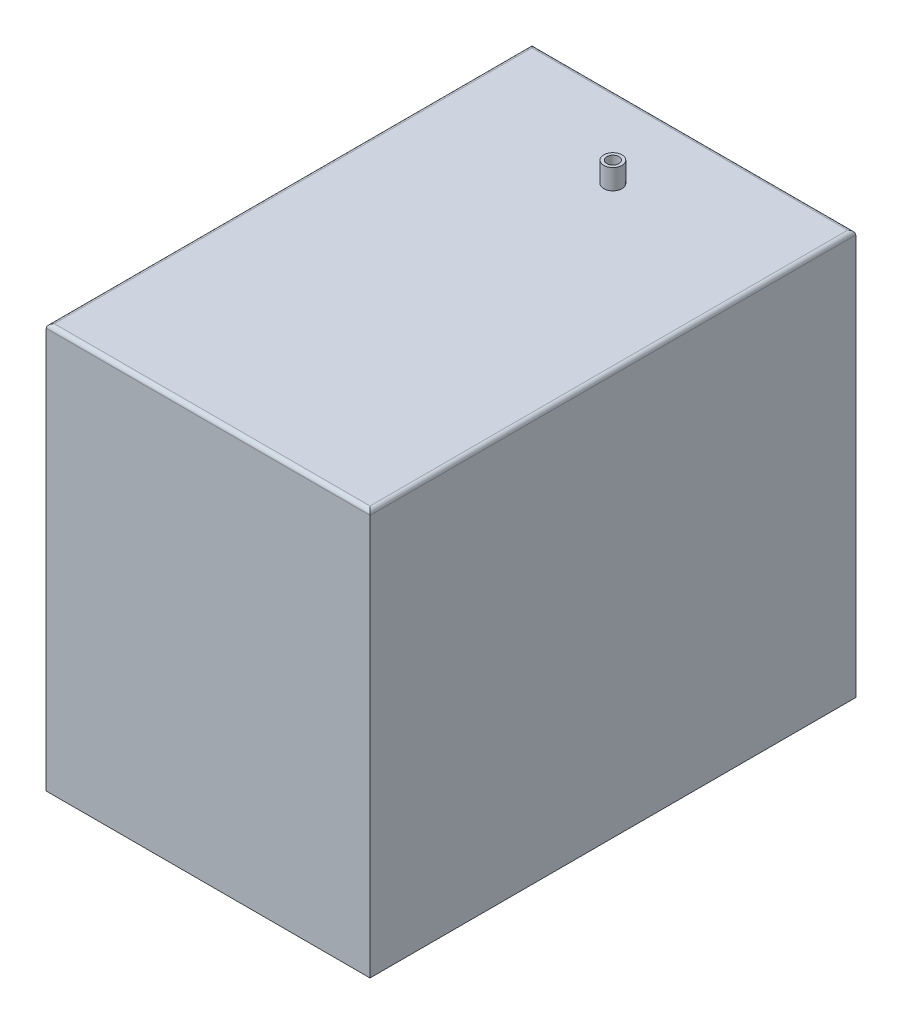
from build123d import *

# Parameters (mm, degrees)
SKETCH1_W           = 80
SKETCH1_H           = 120
BOSS_EXTRUDE1_DEPTH = 100
SKETCH2_R           = 2.25
SKETCH2_R_2         = 1.5
BOSS_EXTRUDE2_DEPTH = 5
FILLET1_R           = 1


with BuildPart() as part:
    # Sketch1 → Boss-Extrude1 (new body)
    with BuildSketch(Plane(origin=(0, 0, 0), x_dir=(1, 0, 0), z_dir=(0, 1, 0))):
        Rectangle(SKETCH1_W, SKETCH1_H)
    extrude(amount=BOSS_EXTRUDE1_DEPTH)

    # Sketch2 → Boss-Extrude2 (add)
    with BuildSketch(Plane(origin=(0, 100, 0), x_dir=(1, 0, 0), z_dir=(0, 1, 0))):
        with Locations((0, 40)):
            Circle(SKETCH2_R)
        with Locations((0, 40)):
            Circle(SKETCH2_R_2, mode=Mode.SUBTRACT)
    extrude(amount=BOSS_EXTRUDE2_DEPTH)

    # Fillet1
    fillet1_edges = [part.edges().sort_by_distance(p)[0] for p in [
        (-40, 100, 0),
        (0, 100, 60),
        (40, 100, 0),
        (0, 100, -60),
    ]]
    fillet(fillet1_edges, radius=FILLET1_R)


solid = part.part
